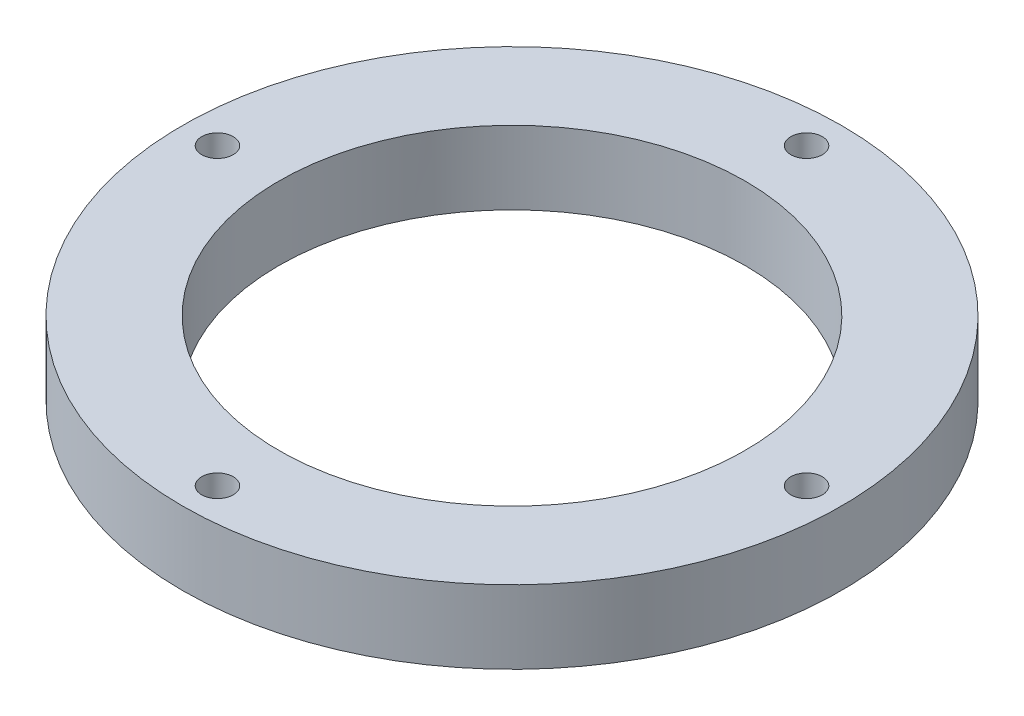
from build123d import *

# Parameters (mm, degrees)
SKETCH2_R               = 45
BOSS_EXTRUDE1_DEPTH     = 10
SKETCH7_R               = 31.85
CUT_EXTRUDE1_DEPTH      = 1
CUT_EXTRUDE1_DEPTH_BACK = 11
SKETCH8_R               = 2.15
CUT_EXTRUDE2_DEPTH      = 11


with BuildPart() as part:
    # Sketch2 → Boss-Extrude1 (new body)
    with BuildSketch(Plane(origin=(0, 0, 0), x_dir=(1, 0, 0), z_dir=(0, 1, 0))):
        Circle(SKETCH2_R)
    extrude(amount=-BOSS_EXTRUDE1_DEPTH)

    # Sketch7 → Cut-Extrude1 (cut, two sides)
    with BuildSketch(Plane(origin=(0, -10, 0), x_dir=(-1, 0, 0), z_dir=(0, -1, 0))) as cut_extrude1_sk:
        Circle(SKETCH7_R)
    extrude(amount=CUT_EXTRUDE1_DEPTH, mode=Mode.SUBTRACT)
    extrude(cut_extrude1_sk.sketch, amount=-CUT_EXTRUDE1_DEPTH_BACK, mode=Mode.SUBTRACT)

    # Sketch8 → Cut-Extrude2 (cut, through all)
    with BuildSketch(Plane.XZ.offset(10)):
        with Locations((-40.22, 0)):
            Circle(SKETCH8_R)
        with Locations((0, -40.22)):
            Circle(SKETCH8_R)
        with Locations((0, 40.22)):
            Circle(SKETCH8_R)
        with Locations((40.22, 0)):
            Circle(SKETCH8_R)
    extrude(amount=-CUT_EXTRUDE2_DEPTH, mode=Mode.SUBTRACT)


solid = part.part
